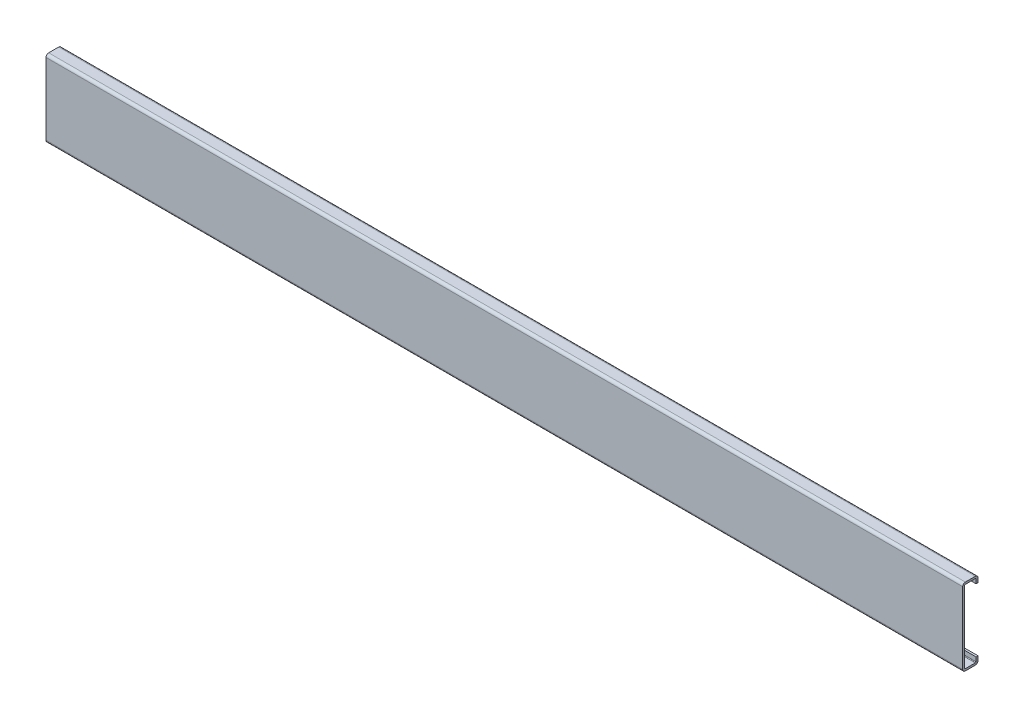
from build123d import *

# Parameters (mm, degrees)
EXTRUDE_1_DEPTH = 550


with BuildPart() as part:
    # Эскиз1 → Вытянуть-Тонкостенный1 (new body)
    with BuildSketch(Plane(origin=(0, 0, 0), x_dir=(0, 0, -1), z_dir=(1, 0, 0))):
        with BuildLine():
            Line((7.4, -19), (7.4, -21.5))
            ThreePointArc((7.4, -21.5), (7.282842712, -21.782842712), (7, -21.9))
            Line((7, -21.9), (1, -21.9))
            ThreePointArc((1, -21.9), (0.717157288, -21.782842712), (0.6, -21.5))
            Line((0.6, -21.5), (0.6, 21.5))
            ThreePointArc((0.6, 21.5), (0.717157288, 21.782842712), (1, 21.9))
            Line((1, 21.9), (7, 21.9))
            ThreePointArc((7, 21.9), (7.282842712, 21.782842712), (7.4, 21.5))
            Line((7.4, 21.5), (7.4, 19))
            Line((7.4, 19), (8.6, 19))
            Line((8.6, 19), (8.6, 21.5))
            ThreePointArc((8.6, 21.5), (8.13137085, 22.63137085), (7, 23.1))
            Line((7, 23.1), (1, 23.1))
            ThreePointArc((1, 23.1), (-0.13137085, 22.63137085), (-0.6, 21.5))
            Line((-0.6, 21.5), (-0.6, -21.5))
            ThreePointArc((-0.6, -21.5), (-0.13137085, -22.63137085), (1, -23.1))
            Line((1, -23.1), (7, -23.1))
            ThreePointArc((7, -23.1), (8.13137085, -22.63137085), (8.6, -21.5))
            Line((8.6, -21.5), (8.6, -19))
            Line((8.6, -19), (7.4, -19))
        make_face()
    extrude(amount=EXTRUDE_1_DEPTH)


solid = part.part
